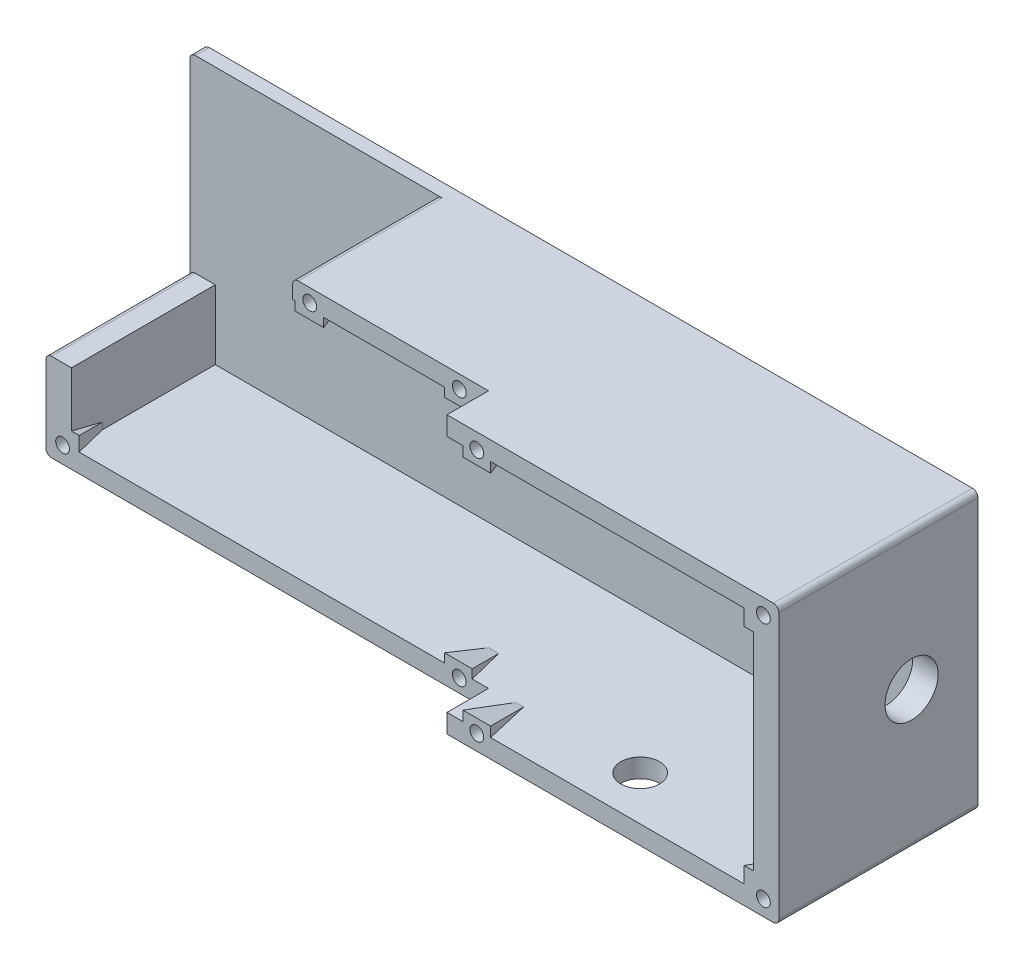
from build123d import *

# Parameters (mm, degrees)
SKETCH1_W           = 177.8
SKETCH1_H           = 63.5
BOSS_EXTRUDE1_DEPTH = 45.72
SKETCH2_W           = 101.6
SKETCH2_H           = 63.5
CUT_EXTRUDE1_DEPTH  = 9.525
SKETCH3_W           = 166.116
SKETCH3_H           = 54.864
CUT_EXTRUDE2_DEPTH  = 42.545
SKETCH4_R           = 6.096
CUT_EXTRUDE3_DEPTH  = 31.75
CUT_EXTRUDE4_START  = -43.18
SKETCH5_R           = 4.445
CUT_EXTRUDE4_DEPTH  = 31.75
SKETCH9_W           = 6.35
SKETCH9_H           = 6.35
SKETCH9_W_2         = 6.565288585
SKETCH9_W_3         = 7.62
SKETCH9_H_2         = 7.62
BOSS_EXTRUDE2_DEPTH = 10.16
BOSS_EXTRUDE2_TAPER = 14
SKETCH6_W           = 56.642
SKETCH6_H           = 43.307
CUT_EXTRUDE5_DEPTH  = 33.02
SKETCH8_R           = 1.5875
CUT_EXTRUDE7_DEPTH  = 4.572
FILLET1_R           = 1.27
FILLET2_R           = 1.27
SKETCH10_W          = 6.35
SKETCH10_H          = 6.604
SKETCH10_W_2        = 7.62
SKETCH10_H_2        = 7.62
BOSS_EXTRUDE3_DEPTH = 10.16
BOSS_EXTRUDE3_TAPER = 13
SKETCH7_R           = 1.5875
CUT_EXTRUDE6_DEPTH  = 4.572
FILLET3_R           = 1.27


with BuildPart() as part:
    # Sketch1 → Boss-Extrude1 (new body)
    with BuildSketch(Plane.XY):
        Rectangle(SKETCH1_W, SKETCH1_H)
    extrude(amount=BOSS_EXTRUDE1_DEPTH)

    # Sketch2 → Cut-Extrude1 (cut)
    with BuildSketch(Plane.XY.offset(45.72)):
        with Locations((-38.1, 0)):
            Rectangle(SKETCH2_W, SKETCH2_H)
    extrude(amount=-CUT_EXTRUDE1_DEPTH, mode=Mode.SUBTRACT)

    # Sketch3 → Cut-Extrude2 (cut)
    with BuildSketch(Plane.XY.offset(45.72)):
        Rectangle(SKETCH3_W, SKETCH3_H)
    extrude(amount=-CUT_EXTRUDE2_DEPTH, mode=Mode.SUBTRACT)

    # Sketch4 → Cut-Extrude3 (cut)
    with BuildSketch(Plane(origin=(88.9, 0, 0), x_dir=(0, 0, -1), z_dir=(1, 0, 0))):
        with Locations((-15.24, 0)):
            Circle(SKETCH4_R)
    extrude(amount=-CUT_EXTRUDE3_DEPTH, mode=Mode.SUBTRACT)

    # Sketch5 → Cut-Extrude4 (cut)
    with BuildSketch(Plane(origin=(0, 31.75, 0), x_dir=(1, 0, 0), z_dir=(0, 1, 0)).offset(CUT_EXTRUDE4_START)):
        with Locations(Location((46.900902689, -35.56, 0), (0, 0, 180))):  # turned: the seam where the file's is
            Circle(SKETCH5_R)
    extrude(amount=-CUT_EXTRUDE4_DEPTH, mode=Mode.SUBTRACT)

    # Sketch9 → Boss-Extrude2 (add)
    with BuildSketch(Plane.XY.offset(36.195)):
        with Locations((5.78513156, 28.575)):
            Rectangle(SKETCH9_W, SKETCH9_H)
        with Locations((-28.41302197, 28.575)):
            Rectangle(SKETCH9_W_2, SKETCH9_H)
        with Locations((5.78513156, -28.575)):
            Rectangle(SKETCH9_W, SKETCH9_H)
        with Locations((-85.09, -27.94)):
            Rectangle(SKETCH9_W_3, SKETCH9_H_2)
    extrude(amount=-BOSS_EXTRUDE2_DEPTH, taper=BOSS_EXTRUDE2_TAPER)

    # Sketch6 → Cut-Extrude5 (cut)
    with BuildSketch(Plane.XY.offset(36.195)):
        with Locations((-60.579, 10.0965)):
            Rectangle(SKETCH6_W, SKETCH6_H)
    extrude(amount=-CUT_EXTRUDE5_DEPTH, mode=Mode.SUBTRACT)

    # Sketch8 → Cut-Extrude7 (cut)
    with BuildSketch(Plane.XY.offset(36.195)):
        with Locations((5.996300657, 28.702)):
            Circle(SKETCH8_R)
        with Locations((-28.340687554, 28.702)):
            Circle(SKETCH8_R)
        with Locations((5.996300657, -28.702)):
            Circle(SKETCH8_R)
        with Locations((-85.09, -27.94)):
            Circle(SKETCH8_R)
    extrude(amount=-CUT_EXTRUDE7_DEPTH, mode=Mode.SUBTRACT)

    # Fillet1
    fillet1_edges = [part.edges().sort_by_distance(p)[0] for p in [
        (-32.258, 31.75, 19.685),
        (-88.9, -31.75, 18.0975),
        (88.9, 31.75, 22.86),
        (88.9, -31.75, 22.86),
    ]]
    fillet(fillet1_edges, radius=FILLET1_R)

    # Fillet2
    fillet2_edges = [part.edges().sort_by_distance(p)[0] for p in [
        (-88.9, -11.557, 19.685),
    ]]
    fillet(fillet2_edges, radius=FILLET2_R)

    # Sketch10 → Boss-Extrude3 (add)
    with BuildSketch(Plane.XY.offset(45.72)):
        with Locations((19.538431576, 28.448)):
            Rectangle(SKETCH10_W, SKETCH10_H)
        with Locations((84.718025612, 27.568025612)):
            Rectangle(SKETCH10_W_2, SKETCH10_H_2)
        with Locations((84.718025612, -27.568025612)):
            Rectangle(SKETCH10_W_2, SKETCH10_H_2)
        with Locations((19.538431576, -28.448)):
            Rectangle(SKETCH10_W, SKETCH10_H)
    extrude(amount=-BOSS_EXTRUDE3_DEPTH, taper=BOSS_EXTRUDE3_TAPER)

    # Sketch7 → Cut-Extrude6 (cut)
    with BuildSketch(Plane.XY.offset(45.72)):
        with Locations((85.344, 28.194)):
            Circle(SKETCH7_R)
        with Locations(Location((85.344, -28.194, 0), (0, 0, 180))):  # turned: the seam where the file's is
            Circle(SKETCH7_R)
        with Locations((19.538431576, 28.194)):
            Circle(SKETCH7_R)
        with Locations((19.538431576, -28.194)):
            Circle(SKETCH7_R)
    extrude(amount=-CUT_EXTRUDE6_DEPTH, mode=Mode.SUBTRACT)

    # Fillet3
    fillet3_edges = [part.edges().sort_by_distance(p)[0] for p in [
        (-88.9, 31.75, 1.5875),
    ]]
    fillet(fillet3_edges, radius=FILLET3_R)


solid = part.part
